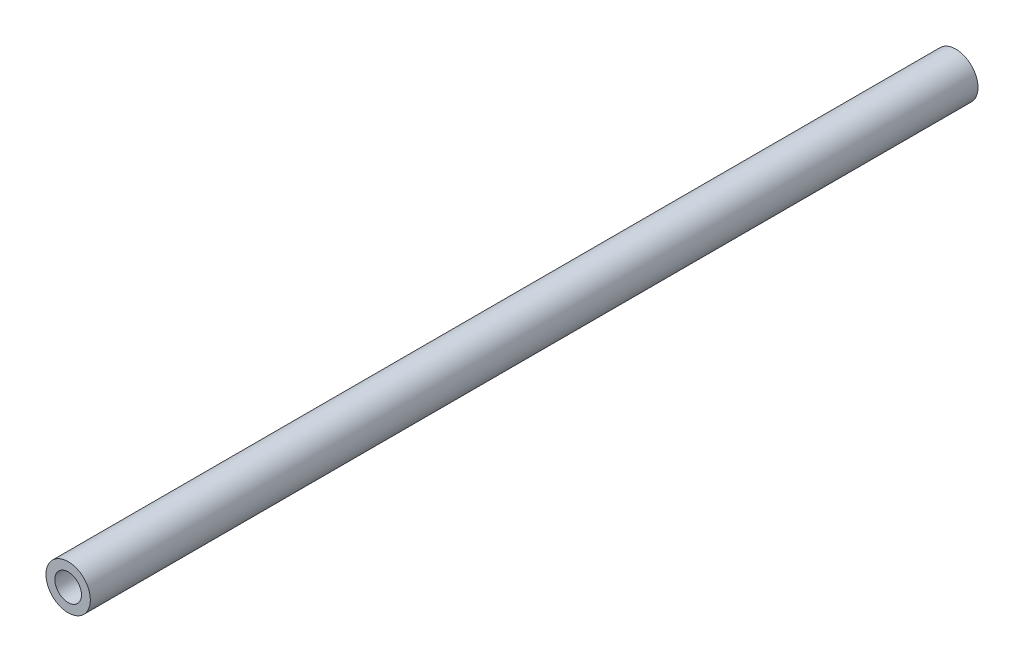
from build123d import *

# Parameters (mm, degrees)
SKETCH1_R           = 7.5
SKETCH1_R_2         = 4.5
BOSS_EXTRUDE1_DEPTH = 300


with BuildPart() as part:
    # Sketch1 → Boss-Extrude1 (new body)
    with BuildSketch(Plane.XY):
        Circle(SKETCH1_R)
        Circle(SKETCH1_R_2, mode=Mode.SUBTRACT)
    extrude(amount=BOSS_EXTRUDE1_DEPTH)


solid = part.part
